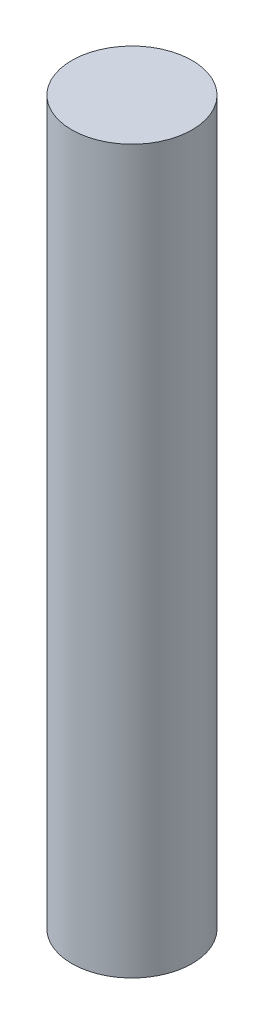
from build123d import *

# Parameters (mm, degrees)
SKETCH1_R           = 1.875
BOSS_EXTRUDE1_DEPTH = 22.5


with BuildPart() as part:
    # Sketch1 → Boss-Extrude1 (new body)
    with BuildSketch(Plane(origin=(0, 0, 0), x_dir=(1, 0, 0), z_dir=(0, 1, 0))):
        Circle(SKETCH1_R)
    extrude(amount=BOSS_EXTRUDE1_DEPTH)


solid = part.part
